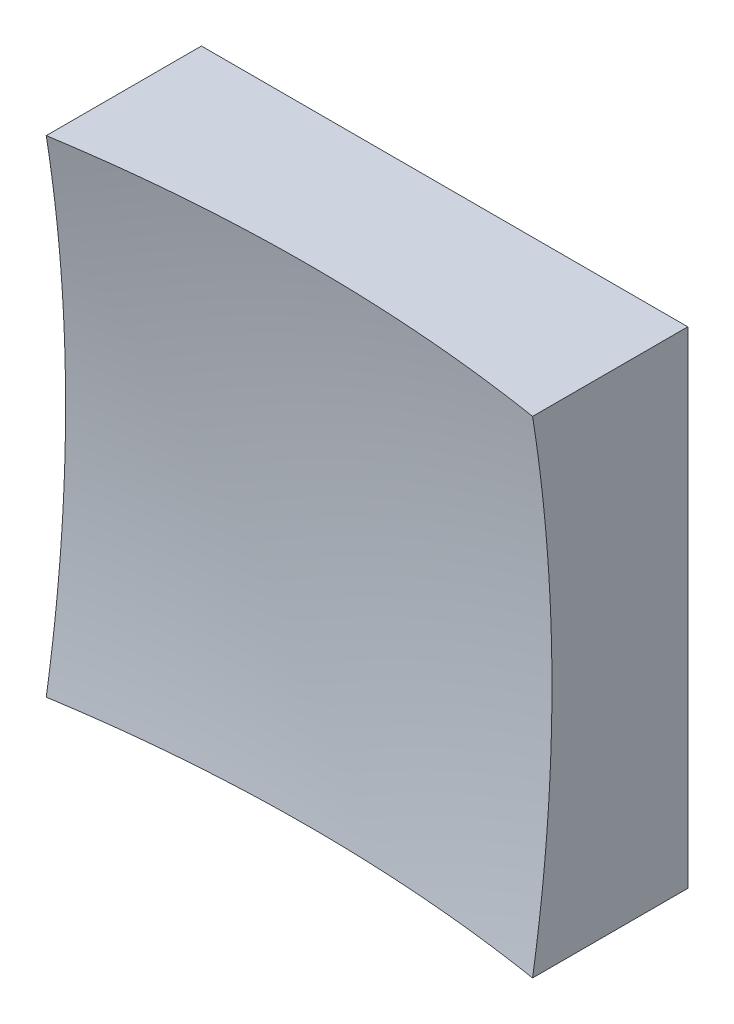
from build123d import *

# Parameters (mm, degrees)
SKETCH_1_W      = 12.5
SKETCH_1_H      = 12.5
EXTRUDE_1_DEPTH = 10


with BuildPart() as part:
    # 草图1 → 凸台-拉伸1 (new body)
    with BuildSketch(Plane.XY):
        Rectangle(SKETCH_1_W, SKETCH_1_H)
    extrude(amount=EXTRUDE_1_DEPTH)

    # 草图2 → 切除-旋转2 (revolve, cut)
    with BuildSketch(Plane(origin=(0, 0, 0), x_dir=(1, 0, 0), z_dir=(0, 1, 0))):
        with BuildLine():
            Line((38.993818473, -34.084725415), (0, -34.084725415))
            Line((0, -34.084725415), (0, -3))
            ThreePointArc((0, -3), (24.933802524, -11.722124565), (38.993818473, -34.084725415))
        make_face()
    revolve(axis=Axis((0, 0, 34.084725415), (0, 0, -1)), mode=Mode.SUBTRACT)


solid = part.part
